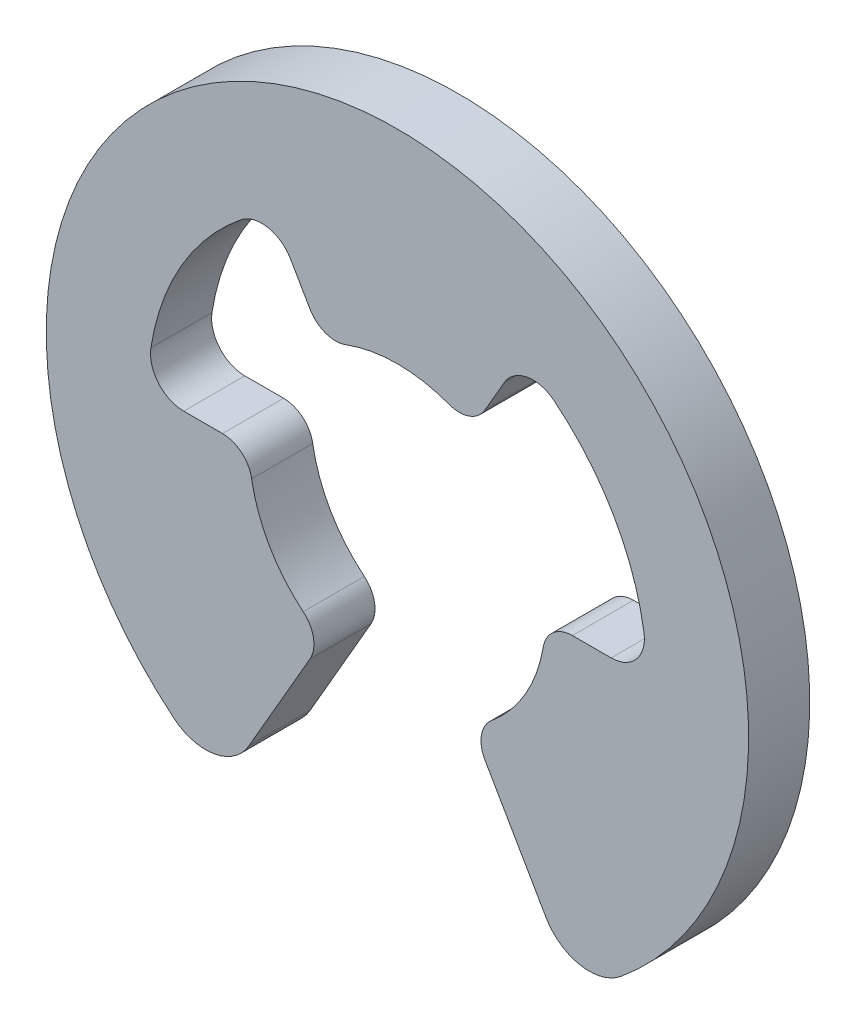
from build123d import *

# Parameters (mm, degrees)
BOSS_EXTRUDE1_DEPTH      = 0.55245
BOSS_EXTRUDE1_DEPTH_BACK = 0.55245


with BuildPart() as part:
    # Sketch1 → Boss-Extrude1 (new, two sides: drawn at the far end of the back side and taken through both)
    with BuildSketch(Plane.XY.offset(-BOSS_EXTRUDE1_DEPTH_BACK)):
        with BuildLine():
            Line((-2.686207619, -4.652648077), (-1.581575189, -2.739368583))
            ThreePointArc((-1.581575189, -2.739368583), (-1.518398027, -2.377324451), (-1.703844152, -2.060027992))
            ThreePointArc((-1.703844152, -2.060027992), (-2.315189002, -1.336675019), (-2.635958642, -0.445558366))
            ThreePointArc((-2.635958642, -0.445558366), (-2.818022364, -0.126309053), (-3.163150378, 0))
            Line((-3.163150378, 0), (-3.863567646, 0))
            ThreePointArc((-3.863567646, 0), (-4.32048273, 0.210277956), (-4.457962671, 0.694103832))
            ThreePointArc((-4.457962671, 0.694103832), (-3.907225167, 2.255837494), (-2.830092898, 3.513656997))
            ThreePointArc((-2.830092898, 3.513656997), (-2.342347424, 3.636508824), (-1.931783823, 3.345947731))
            Line((-1.931783823, 3.345947731), (-1.581575189, 2.739368583))
            ThreePointArc((-1.581575189, 2.739368583), (-1.299624349, 2.503633488), (-0.932114488, 2.505586319))
            ThreePointArc((-0.932114488, 2.505586319), (-1.7e-08, 2.67335), (0.932114457, 2.505586331))
            ThreePointArc((0.932114457, 2.505586331), (1.299624333, 2.503633482), (1.581575189, 2.739368583))
            Line((1.581575189, 2.739368583), (1.931783823, 3.345947731))
            ThreePointArc((1.931783823, 3.345947731), (2.342347445, 3.636508828), (2.830092931, 3.51365697))
            ThreePointArc((2.830092931, 3.51365697), (3.907225174, 2.255837482), (4.457962669, 0.694103846))
            ThreePointArc((4.457962669, 0.694103846), (4.320482735, 0.210277961), (3.863567646, 0))
            Line((3.863567646, 0), (3.163150378, 0))
            ThreePointArc((3.163150378, 0), (2.818022373, -0.126309046), (2.635958646, -0.445558343))
            ThreePointArc((2.635958646, -0.445558343), (2.315189019, -1.33667499), (1.703844185, -2.060027965))
            ThreePointArc((1.703844185, -2.060027965), (1.518398031, -2.377324429), (1.581575189, -2.739368583))
            Line((1.581575189, -2.739368583), (2.686207619, -4.652648077))
            ThreePointArc((2.686207619, -4.652648077), (3.307353322, -5.089462883), (4.042024336, -4.897401277))
            ThreePointArc((4.042024336, -4.897401277), (-2e-08, 6.35), (-4.042024306, -4.897401302))
            ThreePointArc((-4.042024306, -4.897401302), (-3.307353303, -5.08946288), (-2.686207619, -4.652648077))
        make_face()
    extrude(amount=BOSS_EXTRUDE1_DEPTH + BOSS_EXTRUDE1_DEPTH_BACK)


solid = part.part
